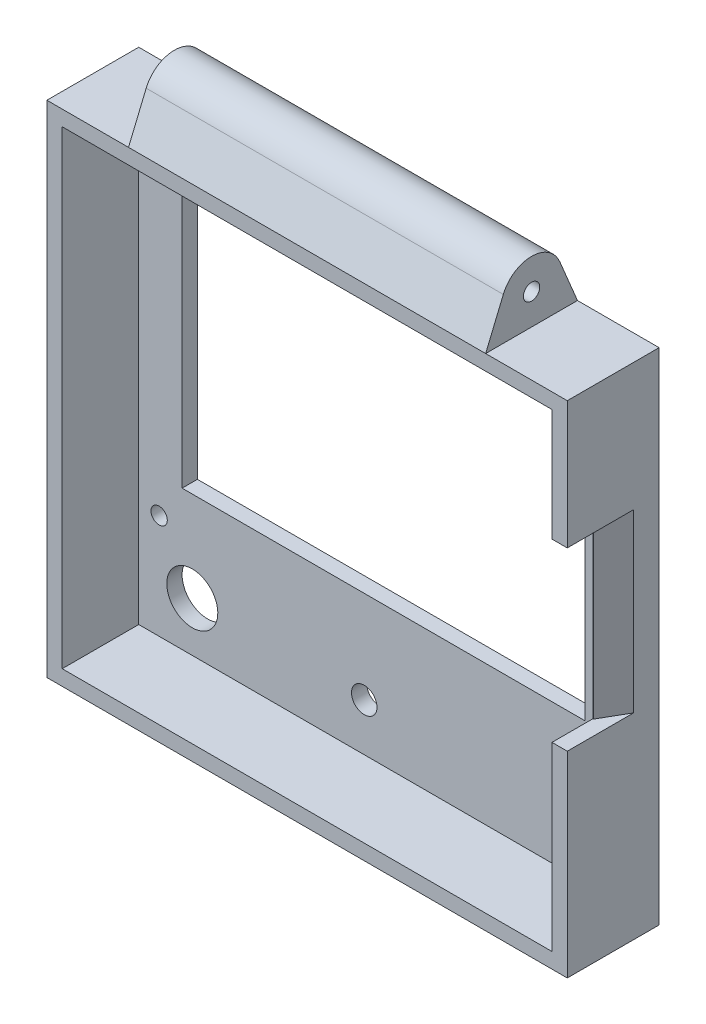
from build123d import *

# Parameters (mm, degrees)
ESBO_O2_W                = 18
ESBO_O2_H                = 98
RESSALTO_EXTRUS_O1_DEPTH = 51
CASCA1_T                 = -3
ESBO_O4_R                = 1.6
ESBO_O4_R_2              = 5
ESBO_O4_R_3              = 3
ESBO_O4_R_4              = 2.5
ESBO_O4_W                = 79
ESBO_O4_H                = 51.6
CORTE_EXTRUS_O1_DEPTH    = 3
ESBO_O5_R                = 1.6
RESSALTO_EXTRUS_O2_DEPTH = 102
ESBO_O6_W                = 16
ESBO_O6_H                = 12
CORTE_EXTRUS_O2_DEPTH    = 19
ESBO_O7_W                = 8
ESBO_O7_H                = 34.5
CORTE_EXTRUS_O3_DEPTH    = 10
CHANFRO1_SIZE            = 5
CHANFRO1_SIZE2           = 2.886751346


with BuildPart() as part:
    # Esboço2 → Ressalto-extrusão1 (new body, symmetric)
    with BuildSketch(Plane(origin=(0, 0, 0), x_dir=(0, 0, -1), z_dir=(1, 0, 0))):
        with Locations((9, 49)):
            Rectangle(ESBO_O2_W, ESBO_O2_H)
    extrude(amount=RESSALTO_EXTRUS_O1_DEPTH, both=True)

    # Casca1
    casca1_openings = [part.faces().sort_by_distance(p)[0] for p in [
        (0, 49, 0),
    ]]
    offset(amount=CASCA1_T, openings=casca1_openings, kind=Kind.INTERSECTION)

    # Esboço4 → Corte-extrusão1 (cut)
    with BuildSketch(Plane(origin=(0, 0, -18), x_dir=(1, 0, 0), z_dir=(0, 0, -1))):
        with Locations((-44, -23.5)):
            Circle(ESBO_O4_R)
        with Locations((-44, -88.5)):
            Circle(ESBO_O4_R)
        with Locations((44, -88.5)):
            Circle(ESBO_O4_R)
        with Locations((44, -23.5)):
            Circle(ESBO_O4_R)
        with Locations((-37.5, -12.7)):
            Circle(ESBO_O4_R_2)
        with Locations((36.75, -15.3)):
            Circle(ESBO_O4_R_3)
        with Locations((-3.8, -12.3)):
            Circle(ESBO_O4_R_4)
        with Locations((0, -56.2)):
            Rectangle(ESBO_O4_W, ESBO_O4_H)
    extrude(amount=-CORTE_EXTRUS_O1_DEPTH, mode=Mode.SUBTRACT)

    # Esboço5 → Ressalto-extrusão2 (add, through all)
    with BuildSketch(Plane(origin=(51, 0, 0), x_dir=(0, 0, -1), z_dir=(1, 0, 0))):
        with BuildLine():
            Line((14.538461538, 106.307692308), (18, 98))
            Line((18, 98), (0, 98))
            Line((0, 98), (3.461538462, 106.307692308))
            ThreePointArc((3.461538462, 106.307692308), (9, 110), (14.538461538, 106.307692308))
        make_face()
        with Locations((9, 104)):
            Circle(ESBO_O5_R, mode=Mode.SUBTRACT)
    extrude(amount=-RESSALTO_EXTRUS_O2_DEPTH)

    # Esboço6 → Corte-extrusão2 (cut, through all)
    with BuildSketch(Plane(origin=(0, 0, -18), x_dir=(-1, 0, 0), z_dir=(0, 0, -1))):
        with Locations((-43, 104)):
            Rectangle(ESBO_O6_W, ESBO_O6_H)
        with Locations((43, 104)):
            Rectangle(ESBO_O6_W, ESBO_O6_H)
    extrude(amount=-CORTE_EXTRUS_O2_DEPTH, mode=Mode.SUBTRACT)

    # Esboço7 → Corte-extrusão3 (cut)
    with BuildSketch(Plane(origin=(51, 0, 0), x_dir=(0, 0, -1), z_dir=(1, 0, 0))):
        with Locations((4, 55.75)):
            Rectangle(ESBO_O7_W, ESBO_O7_H)
    extrude(amount=-CORTE_EXTRUS_O3_DEPTH, mode=Mode.SUBTRACT)

    # Chanfro1
    chanfro1_edges = [part.edges().sort_by_distance(p)[0] for p in [
        (51, 55.75, -8),
    ]]
    chanfro1_side = [part.faces().sort_by_distance(p)[0] for p in [
        (51, 47.747983871, -9.927419355),
    ]]
    chamfer(chanfro1_edges, length=CHANFRO1_SIZE, length2=CHANFRO1_SIZE2, reference=chanfro1_side[0])


solid = part.part
